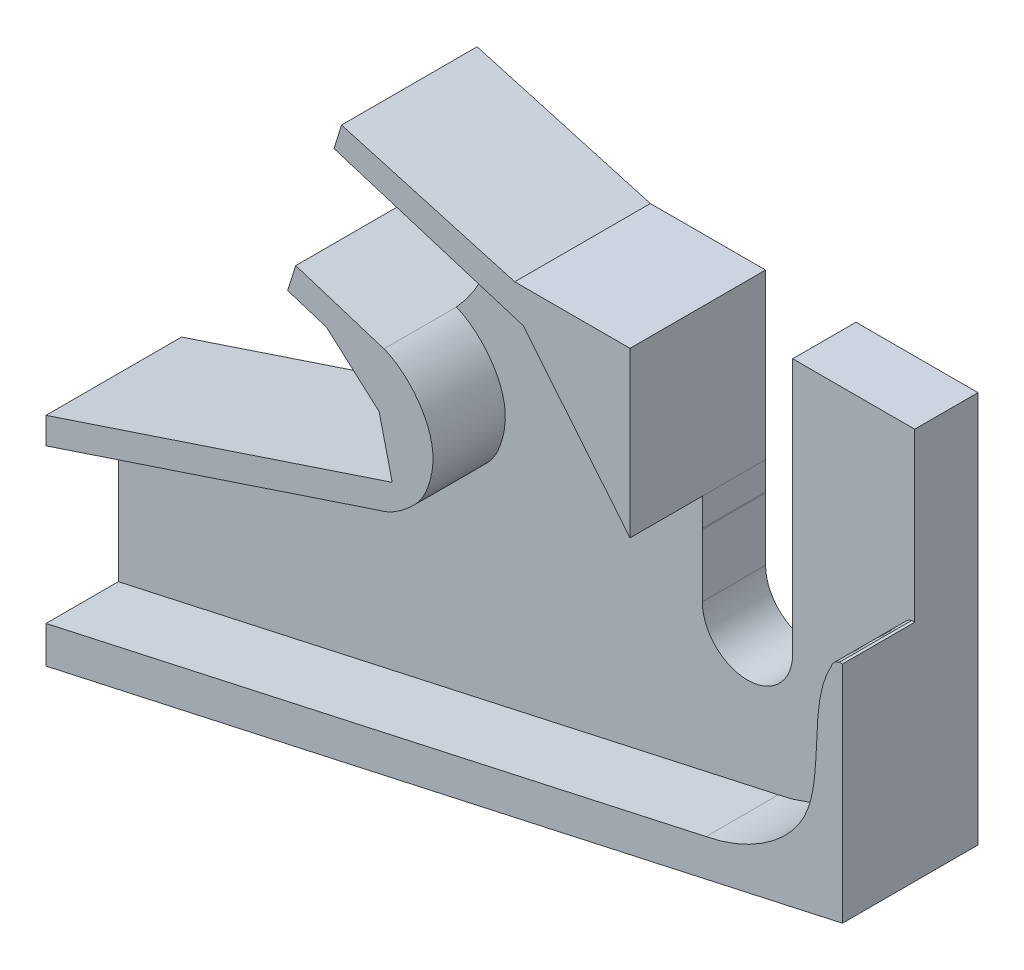
from build123d import *

# Parameters (mm, degrees)
BOSS_EXTRUDE1_DEPTH = 7
BOSS_EXTRUDE3_DEPTH = 15


with BuildPart() as part:
    # Sketch2 → Boss-Extrude1 (new body)
    with BuildSketch(Plane.XY):
        with BuildLine():
            Line((46.285916799, 119.634724339), (134.396340404, 139.050413551))
            Line((134.396340404, 139.050413551), (134.39379389, 182.38704377))
            Line((134.39379389, 182.38704377), (120.894388682, 182.386250529))
            Line((120.894388682, 182.386250529), (120.894655408, 177.847108131))
            Line((120.894655408, 177.847108131), (120.895456025, 177.847108131))
            Line((120.895456025, 177.847108131), (120.895456025, 154.100245399))
            ThreePointArc((120.895456025, 154.100245399), (115.895456025, 149.100245399), (110.895456025, 154.100245399))
            Line((110.895456025, 154.100245399), (110.895456025, 164.221886849))
            Line((110.895456025, 164.221886849), (110.894388699, 182.385662916))
            Line((110.894388699, 182.385662916), (98.145136748, 182.384913754))
            Line((98.145136748, 182.384913754), (78.980988049, 187.822713754))
            Line((78.980988049, 187.822713754), (78.151086328, 185.147461295))
            Line((78.151086328, 185.147461295), (88.076413708, 182.068482243))
            add(Edge.make_bspline(
                [(83.678693998, 168.728153838), (88.77463375, 174.312097996), (88.076413708, 182.068482243)],
                knots=[0, 0, 0, 1, 1, 1], degree=2))
            Line((83.678693998, 168.728153838), (73.917241092, 171.824383576))
            Line((73.917241092, 171.824383576), (73.018341013, 168.990430176))
            Line((73.018341013, 168.990430176), (77.298136398, 167.632924294))
            Line((77.298136398, 167.632924294), (83.134894854, 162.46237946))
            Line((83.134894854, 162.46237946), (84.589439396, 156.392019708))
            Line((84.589439396, 156.392019708), (46.285916799, 143.661523495))
            Line((46.285916799, 143.661523495), (46.285916799, 119.634724339))
        make_face()
    extrude(amount=BOSS_EXTRUDE1_DEPTH)

    # Sketch2_5 → Boss-Extrude3 (add)
    with BuildSketch(Plane.XY):
        Polygon((87.058472282, 182.384262288), (88.076413708, 182.068482243), (99.075977115, 178.656259752), (110.895456025, 164.221886849), (110.895184282, 168.846419808), (110.894388699, 182.385662916), (98.145136748, 182.384913754), align=None)
        Polygon((78.151086328, 185.147461295), (87.058472282, 182.384262288), (98.145136748, 182.384913754), (78.980988049, 187.822713754), align=None)
        with BuildLine():
            Line((46.285916799, 143.661523495), (46.285916799, 140.73837931))
            Line((46.285916799, 140.73837931), (83.134894854, 152.985445474))
            add(Edge.make_bspline(
                [(83.134894854, 152.985445474), (84.174927516, 153.23074968), (85.840748742, 154.28331709), (87.795600381, 156.094817729), (88.836774052, 158.514861149), (89.609824294, 162.728645553), (87.029154532, 166.875865112), (84.288075, 168.507673549), (83.678693998, 168.728153838)],
                knots=[0, 0, 0, 0, 0.137401343, 0.255123746, 0.340171857, 0.476918897, 0.801613812, 0.887468334, 0.887468334, 0.887468334, 0.887468334], degree=3))
            Line((83.678693998, 168.728153838), (83.308823, 168.845473012))
            add(Edge.make_bspline(
                [(83.308823, 168.845473012), (82.615828523, 169.034245679), (81.877979683, 169.060179847), (81.093974035, 168.846419773)],
                knots=[0.904634429, 0.904634429, 0.904634429, 0.904634429, 1, 1, 1, 1], degree=3))
            Line((81.093974035, 168.846419773), (77.298136398, 167.632924294))
            Line((77.298136398, 167.632924294), (83.134894854, 162.46237946))
            Line((83.134894854, 162.46237946), (84.589439396, 156.392019708))
            Line((84.589439396, 156.392019708), (46.285916799, 143.661523495))
        make_face()
        with BuildLine():
            Line((73.018341013, 168.990430176), (77.298136398, 167.632924294))
            Line((77.298136398, 167.632924294), (81.093974035, 168.846419773))
            add(Edge.make_bspline(
                [(83.308823, 168.845473012), (82.615828523, 169.034245679), (81.877979683, 169.060179847), (81.093974035, 168.846419773)],
                knots=[0.904634429, 0.904634429, 0.904634429, 0.904634429, 1, 1, 1, 1], degree=3))
            Line((83.308823, 168.845473012), (73.917241092, 171.824383576))
            Line((73.917241092, 171.824383576), (73.018341013, 168.990430176))
        make_face()
        with BuildLine():
            Line((119.308499738, 139.814661997), (46.285916799, 123.723673918))
            Line((46.285916799, 123.723673918), (46.285916799, 119.634724339))
            Line((46.285916799, 119.634724339), (134.396340404, 139.050413551))
            Line((134.396340404, 139.050413551), (134.394880743, 163.890947893))
            Line((134.394880743, 163.890947893), (134.0570987, 163.890947893))
            add(Edge.make_bspline(
                [(133.108709045, 162.9170571), (133.328673606, 163.695225929), (134.0570987, 163.890947893)],
                knots=[0, 0, 0, 1, 1, 1], degree=2))
            add(Edge.make_bspline(
                [(119.308499738, 139.814661997), (123.463953154, 140.563007639), (134.082921071, 146.527888), (130.556655112, 158.461365551), (133.108709045, 162.9170571)],
                knots=[0, 0, 0, 0, 0.463455576, 1, 1, 1, 1], degree=3))
        make_face()
    extrude(amount=BOSS_EXTRUDE3_DEPTH)


solid = part.part
